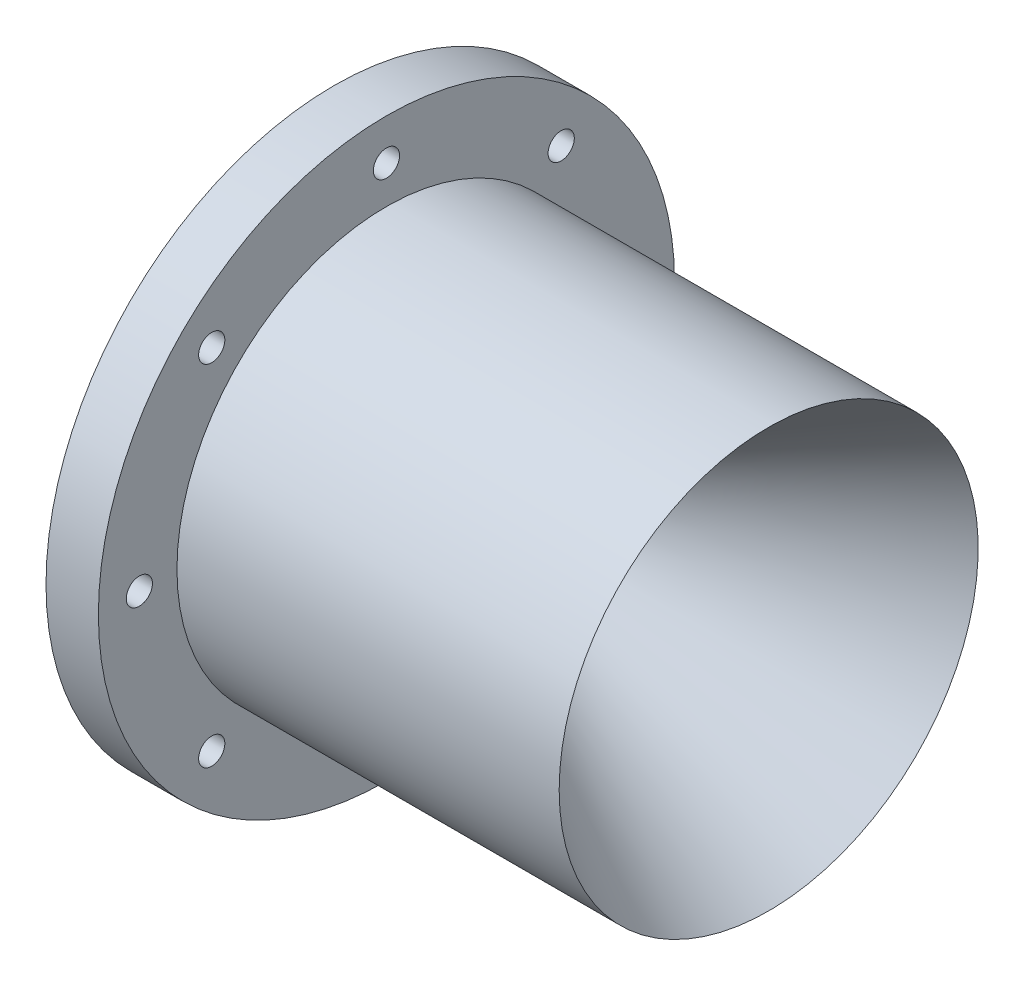
from build123d import *

# Parameters (mm, degrees)
CUT_EXTRUDE2_REACH = 107.371
SKETCH3_R          = 3.175


with BuildPart() as part:
    # Sketch1 → Revolve1 (revolve)
    with BuildSketch(Plane.XY):
        Polygon((0, 7.9375), (72.324156056, 50.8), (-20.347266862, 50.8), (-20.347266862, 69.85), (-33.047266862, 69.85), (-33.047266862, 50.8), (-33.047266862, 41.275), (-12.7, 7.9375), align=None)
    revolve(axis=Axis((0, 0, 0), (1, 0, 0)))

    # Sketch3 → Cut-Extrude2 (cut, up to next)
    with BuildSketch(Plane.ZY.offset(33.047266862), mode=Mode.PRIVATE) as cut_extrude2_sk1:
        with Locations((0, 59.9186)):
            Circle(SKETCH3_R)
    cut_extrude2_tool1 = extrude(cut_extrude2_sk1.sketch, amount=-CUT_EXTRUDE2_REACH, mode=Mode.PRIVATE) & part.part
    add(cut_extrude2_tool1.solids().sort_by_distance((-33.047267, 59.9186, 0))[0], mode=Mode.SUBTRACT)
    # Sketch3 → Cut-Extrude2 (cut, up to next)
    with BuildSketch(Plane.ZY.offset(33.047266862), mode=Mode.PRIVATE) as cut_extrude2_sk2:
        with Locations((42.368848379, 42.368848379)):
            Circle(SKETCH3_R)
    cut_extrude2_tool2 = extrude(cut_extrude2_sk2.sketch, amount=-CUT_EXTRUDE2_REACH, mode=Mode.PRIVATE) & part.part
    add(cut_extrude2_tool2.solids().sort_by_distance((-33.047267, 42.368848, 42.368848))[0], mode=Mode.SUBTRACT)
    # Sketch3 → Cut-Extrude2 (cut, up to next)
    with BuildSketch(Plane.ZY.offset(33.047266862), mode=Mode.PRIVATE) as cut_extrude2_sk3:
        with Locations((59.9186, 0)):
            Circle(SKETCH3_R)
    cut_extrude2_tool3 = extrude(cut_extrude2_sk3.sketch, amount=-CUT_EXTRUDE2_REACH, mode=Mode.PRIVATE) & part.part
    add(cut_extrude2_tool3.solids().sort_by_distance((-33.047267, 0, 59.9186))[0], mode=Mode.SUBTRACT)
    # Sketch3 → Cut-Extrude2 (cut, up to next)
    with BuildSketch(Plane.ZY.offset(33.047266862), mode=Mode.PRIVATE) as cut_extrude2_sk4:
        with Locations((42.368848379, -42.368848379)):
            Circle(SKETCH3_R)
    cut_extrude2_tool4 = extrude(cut_extrude2_sk4.sketch, amount=-CUT_EXTRUDE2_REACH, mode=Mode.PRIVATE) & part.part
    add(cut_extrude2_tool4.solids().sort_by_distance((-33.047267, -42.368848, 42.368848))[0], mode=Mode.SUBTRACT)
    # Sketch3 → Cut-Extrude2 (cut, up to next)
    with BuildSketch(Plane.ZY.offset(33.047266862), mode=Mode.PRIVATE) as cut_extrude2_sk5:
        with Locations((0, -59.9186)):
            Circle(SKETCH3_R)
    cut_extrude2_tool5 = extrude(cut_extrude2_sk5.sketch, amount=-CUT_EXTRUDE2_REACH, mode=Mode.PRIVATE) & part.part
    add(cut_extrude2_tool5.solids().sort_by_distance((-33.047267, -59.9186, 0))[0], mode=Mode.SUBTRACT)
    # Sketch3 → Cut-Extrude2 (cut, up to next)
    with BuildSketch(Plane.ZY.offset(33.047266862), mode=Mode.PRIVATE) as cut_extrude2_sk6:
        with Locations((-42.368848379, -42.368848379)):
            Circle(SKETCH3_R)
    cut_extrude2_tool6 = extrude(cut_extrude2_sk6.sketch, amount=-CUT_EXTRUDE2_REACH, mode=Mode.PRIVATE) & part.part
    add(cut_extrude2_tool6.solids().sort_by_distance((-33.047267, -42.368848, -42.368848))[0], mode=Mode.SUBTRACT)
    # Sketch3 → Cut-Extrude2 (cut, up to next)
    with BuildSketch(Plane.ZY.offset(33.047266862), mode=Mode.PRIVATE) as cut_extrude2_sk7:
        with Locations((-59.9186, 0)):
            Circle(SKETCH3_R)
    cut_extrude2_tool7 = extrude(cut_extrude2_sk7.sketch, amount=-CUT_EXTRUDE2_REACH, mode=Mode.PRIVATE) & part.part
    add(cut_extrude2_tool7.solids().sort_by_distance((-33.047267, 0, -59.9186))[0], mode=Mode.SUBTRACT)
    # Sketch3 → Cut-Extrude2 (cut, up to next)
    with BuildSketch(Plane.ZY.offset(33.047266862), mode=Mode.PRIVATE) as cut_extrude2_sk8:
        with Locations((-42.368848379, 42.368848379)):
            Circle(SKETCH3_R)
    cut_extrude2_tool8 = extrude(cut_extrude2_sk8.sketch, amount=-CUT_EXTRUDE2_REACH, mode=Mode.PRIVATE) & part.part
    add(cut_extrude2_tool8.solids().sort_by_distance((-33.047267, 42.368848, -42.368848))[0], mode=Mode.SUBTRACT)


solid = part.part
